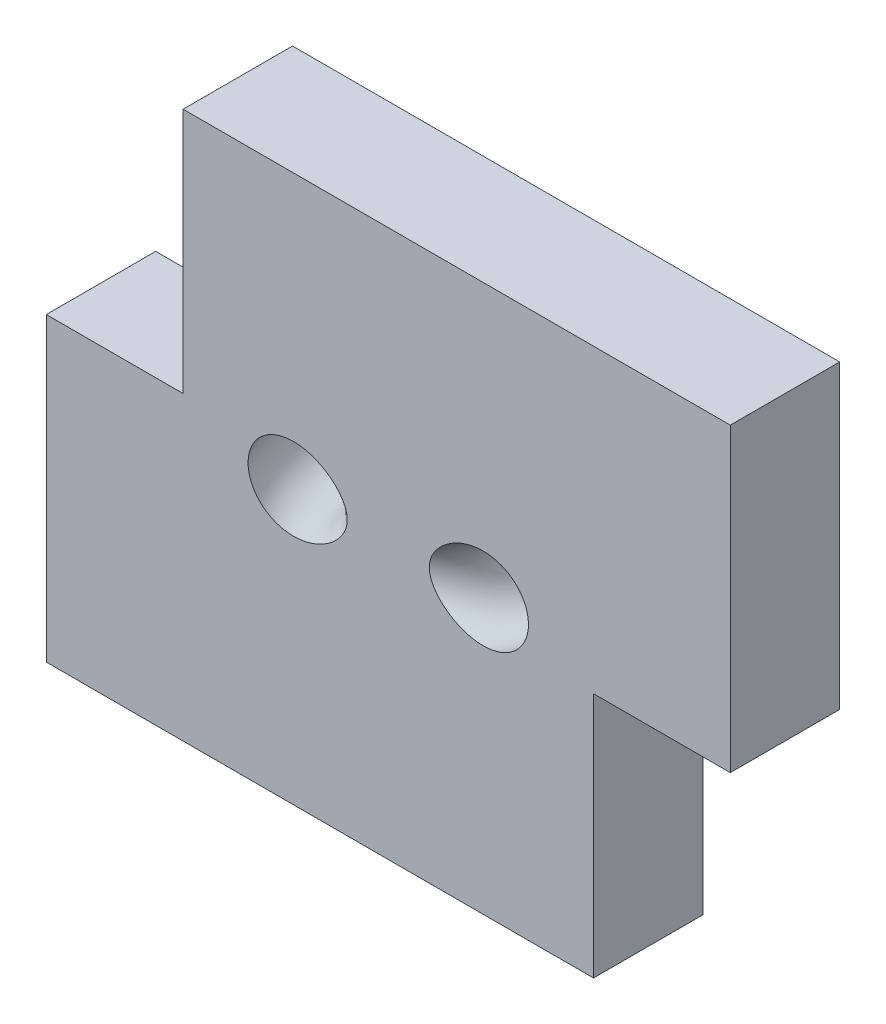
from build123d import *

# Parameters (mm, degrees)
BOSS_EXTRUDE1_DEPTH      = 10
BOSS_EXTRUDE1_DEPTH_BACK = 10
SKETCH2_R                = 7.5


with BuildPart() as part:
    # Sketch1 → Boss-Extrude1 (new, two sides: drawn at the far end of the back side and taken through both)
    with BuildSketch(Plane.XY.offset(-BOSS_EXTRUDE1_DEPTH_BACK)):
        Polygon((0, 0), (100, 0), (100, 45), (125, 45), (125, 100), (25, 100), (25, 55), (0, 55), align=None)
    extrude(amount=BOSS_EXTRUDE1_DEPTH + BOSS_EXTRUDE1_DEPTH_BACK)

    # Sketch2 → Cut-Revolve2 (revolve, cut)
    with BuildSketch(Plane.XY):
        with Locations((82.5, 50)):
            Circle(SKETCH2_R)
    revolve(axis=Axis((62.5, 50.212189842, 0), (0, -1, 0)), mode=Mode.SUBTRACT)


solid = part.part
